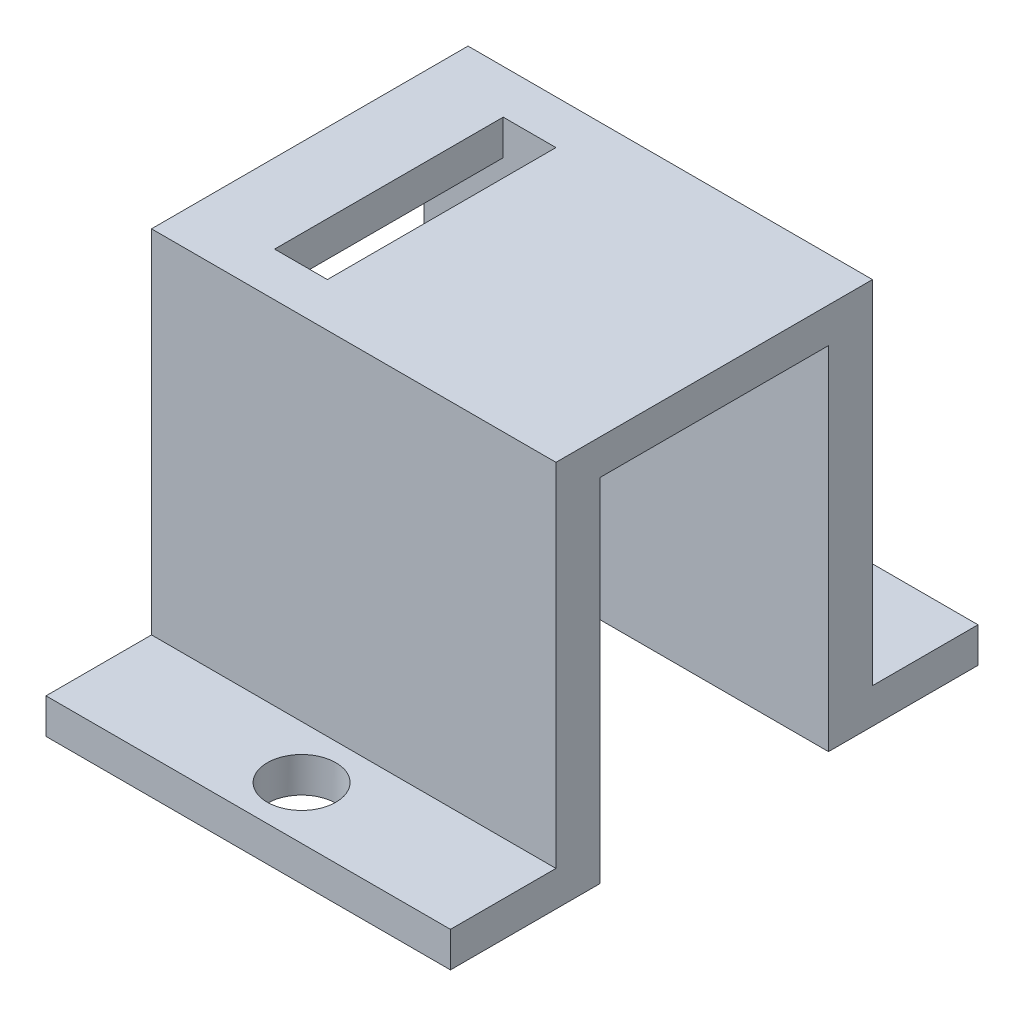
from build123d import *

# Parameters (mm, degrees)
ESQUISSE1_W             = 23
ESQUISSE1_H             = 30
BOSS_EXTRU_1_DEPTH      = 22
ESQUISSE2_W             = 23
ESQUISSE2_H             = 6
ENL_V_MAT_EXTRU_1_DEPTH = 20
D_GAGEMENT_M3_51_D      = 3.9
D_GAGEMENT_M3_51_DEPTH  = 5
D_GAGEMENT_M3_51_TIP    = 1.171678207
ESQUISSE5_W             = 3
ESQUISSE5_H             = 13
ENL_V_MAT_EXTRU_2_DEPTH = 23
ESQUISSE6_W             = 24.5
ESQUISSE6_H             = 13
ENL_V_MAT_EXTRU_3_DEPTH = 20


with BuildPart() as part:
    # Esquisse1 → Boss.-Extru.1 (new body)
    with BuildSketch(Plane(origin=(0, 0, 0), x_dir=(1, 0, 0), z_dir=(0, 1, 0))):
        with Locations((11.5, 15)):
            Rectangle(ESQUISSE1_W, ESQUISSE1_H)
    extrude(amount=BOSS_EXTRU_1_DEPTH)

    # Esquisse2 → Enlèv. mat.-Extru.1 (cut)
    with BuildSketch(Plane(origin=(0, 22, 0), x_dir=(1, 0, 0), z_dir=(0, 1, 0))):
        with Locations((11.5, 27)):
            Rectangle(ESQUISSE2_W, ESQUISSE2_H)
        with Locations((11.5, 3)):
            Rectangle(ESQUISSE2_W, ESQUISSE2_H)
    extrude(amount=-ENL_V_MAT_EXTRU_1_DEPTH, mode=Mode.SUBTRACT)

    # Dégagement M3.51
    with Locations(Plane(origin=(0, 2, 0), x_dir=(1, 0, 0), z_dir=(0, 1, 0))):
        with Locations((11.534470398, 27), (11.534470398, 3)):
            Hole(D_GAGEMENT_M3_51_D / 2, depth=D_GAGEMENT_M3_51_DEPTH)
            with Locations((0, 0, -(D_GAGEMENT_M3_51_DEPTH + D_GAGEMENT_M3_51_TIP / 2))):  # 118° drill point
                Cone(0, D_GAGEMENT_M3_51_D / 2, D_GAGEMENT_M3_51_TIP, mode=Mode.SUBTRACT)

    # Esquisse5 → Enlèv. mat.-Extru.2 (cut, through all)
    with BuildSketch(Plane(origin=(0, 22, 0), x_dir=(1, 0, 0), z_dir=(0, 1, 0))):
        with Locations((6, 15)):
            Rectangle(ESQUISSE5_W, ESQUISSE5_H)
    extrude(amount=-ENL_V_MAT_EXTRU_2_DEPTH, mode=Mode.SUBTRACT)

    # Esquisse6 → Enlèv. mat.-Extru.3 (cut)
    with BuildSketch(Plane.XZ):
        with Locations((12.25, -15)):
            Rectangle(ESQUISSE6_W, ESQUISSE6_H)
    extrude(amount=-ENL_V_MAT_EXTRU_3_DEPTH, mode=Mode.SUBTRACT)


solid = part.part
